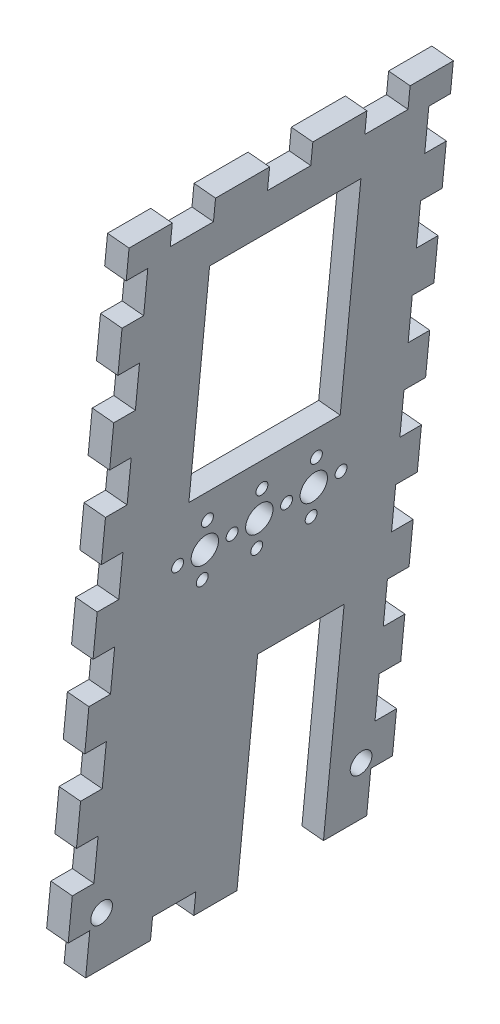
from build123d import *

# Parameters (mm, degrees)
BOSS_EXTRUDE1_DEPTH = 95.25
SKETCH3_R           = 3.175
CUT_EXTRUDE1_DEPTH  = 26.366155757
SKETCH4_R           = 4
SKETCH4_R_2         = 1.75
CUT_EXTRUDE2_DEPTH  = 26.366155757
LPATTERN1_COUNT     = 2
LPATTERN1_PITCH     = 16
LPATTERN1_COL_COUNT = 2
LPATTERN1_COL_PITCH = 16
SKETCH5_W           = 44.45
SKETCH5_H           = 63.5
CUT_EXTRUDE3_DEPTH  = 26.366155757
SKETCH6_W           = 25.4
SKETCH6_H           = 63.5
CUT_EXTRUDE4_DEPTH  = 26.366155757
SKETCH8_W           = 6.35
SKETCH8_H           = 12.7
CUT_EXTRUDE6_DEPTH  = 26.366155757
LPATTERN2_COUNT     = 18
LPATTERN2_PITCH     = 25.4
SKETCH9_W           = 12.7
SKETCH9_H           = 6.403441613
CUT_EXTRUDE7_DEPTH  = 26.366155757
SKETCH10_W          = 12.7
SKETCH10_H          = 6.35
CUT_EXTRUDE8_DEPTH  = 26.366155757


with BuildPart() as part:
    # Sketch2 → Boss-Extrude1 (new body)
    with BuildSketch(Plane.XY):
        Polygon((38.583668647, 0.58465909), (44.904434507, -0.023961438), (64.008541785, 198.379778502), (57.687775925, 198.988399031), align=None)
    extrude(amount=BOSS_EXTRUDE1_DEPTH)

    # Sketch3 → Cut-Extrude1 (cut, through all)
    with BuildSketch(Plane(origin=(38.173444207, -3.675684609, 0), x_dir=(0, 0, 1), z_dir=(-0.995396198, 0.095845753, 0))):
        with Locations((9.525, 20.155048192)):
            Circle(SKETCH3_R)
        with Locations((85.725, 20.155048192)):
            Circle(SKETCH3_R)
    extrude(amount=-CUT_EXTRUDE1_DEPTH, mode=Mode.SUBTRACT)

    # Sketch4 → Cut-Extrude2 (cut, through all)
    with BuildSketch(Plane(origin=(38.173444207, -3.675684609, 0), x_dir=(0, 0, 1), z_dir=(-0.995396198, 0.095845753, 0))):
        with Locations((47.625, 105.880048192)):
            Circle(SKETCH4_R)
        with Locations((47.625, 113.880048192)):
            Circle(SKETCH4_R_2)
        with Locations((55.625, 105.880048192)):
            Circle(SKETCH4_R_2)
        with Locations((47.625, 97.880048192)):
            Circle(SKETCH4_R_2)
        with Locations((39.625, 105.880048192)):
            Circle(SKETCH4_R_2)
    cut_extrude2 = extrude(amount=-CUT_EXTRUDE2_DEPTH, mode=Mode.SUBTRACT)

    # LPattern1: Cut-Extrude2 ×2
    with Locations(*[(0, 0, i * LPATTERN1_PITCH) for i in range(1, LPATTERN1_COUNT)]):
        add(cut_extrude2, mode=Mode.SUBTRACT)

    # LPattern1 col: Cut-Extrude2 ×2
    with Locations(*[(0, 0, -i * LPATTERN1_COL_PITCH) for i in range(1, LPATTERN1_COL_COUNT)]):
        add(cut_extrude2, mode=Mode.SUBTRACT)

    # Sketch5 → Cut-Extrude3 (cut, through all)
    with BuildSketch(Plane(origin=(38.173444207, -3.675684609, 0), x_dir=(0, 0, 1), z_dir=(-0.995396198, 0.095845753, 0))):
        with Locations((47.625, 153.630048192)):
            Rectangle(SKETCH5_W, SKETCH5_H)
    extrude(amount=-CUT_EXTRUDE3_DEPTH, mode=Mode.SUBTRACT)

    # Sketch6 → Cut-Extrude4 (cut, through all)
    with BuildSketch(Plane(origin=(38.173444207, -3.675684609, 0), x_dir=(0, 0, 1), z_dir=(-0.995396198, 0.095845753, 0))):
        with Locations((31.75, 36.030048192)):
            Rectangle(SKETCH6_W, SKETCH6_H)
    extrude(amount=-CUT_EXTRUDE4_DEPTH, mode=Mode.SUBTRACT)

    # Sketch8 → Cut-Extrude6 (cut, through all)
    with BuildSketch(Plane(origin=(38.173444207, -3.675684609, 0), x_dir=(0, 0, 1), z_dir=(-0.995396198, 0.095845753, 0))):
        with Locations((3.175, 10.630048192)):
            Rectangle(SKETCH8_W, SKETCH8_H)
        with Locations((92.075, 10.630048192)):
            Rectangle(SKETCH8_W, SKETCH8_H)
    cut_extrude6 = extrude(amount=-CUT_EXTRUDE6_DEPTH, mode=Mode.SUBTRACT)

    # LPattern2: Cut-Extrude6 ×18
    with Locations(*[Vector(0.095845753, 0.995396198, 0) * (i * LPATTERN2_PITCH) for i in range(1, LPATTERN2_COUNT)]):
        add(cut_extrude6, mode=Mode.SUBTRACT)

    # Sketch9 → Cut-Extrude7 (cut, through all)
    with BuildSketch(Plane(origin=(38.173444207, -3.675684609, 0), x_dir=(0, 0, 1), z_dir=(-0.995396198, 0.095845753, 0))):
        with Locations((63.5, 7.481768999)):
            Rectangle(SKETCH9_W, SKETCH9_H)
    extrude(amount=-CUT_EXTRUDE7_DEPTH, mode=Mode.SUBTRACT)

    # Sketch10 → Cut-Extrude8 (cut, through all)
    with BuildSketch(Plane(origin=(38.173444207, -3.675684609, 0), x_dir=(0, 0, 1), z_dir=(-0.995396198, 0.095845753, 0))):
        with Locations((19.05, 200.426424209)):
            Rectangle(SKETCH10_W, SKETCH10_H)
        with Locations((47.625, 200.426424209)):
            Rectangle(SKETCH10_W, SKETCH10_H)
        with Locations((76.2, 200.426424209)):
            Rectangle(SKETCH10_W, SKETCH10_H)
    extrude(amount=-CUT_EXTRUDE8_DEPTH, mode=Mode.SUBTRACT)


solid = part.part
